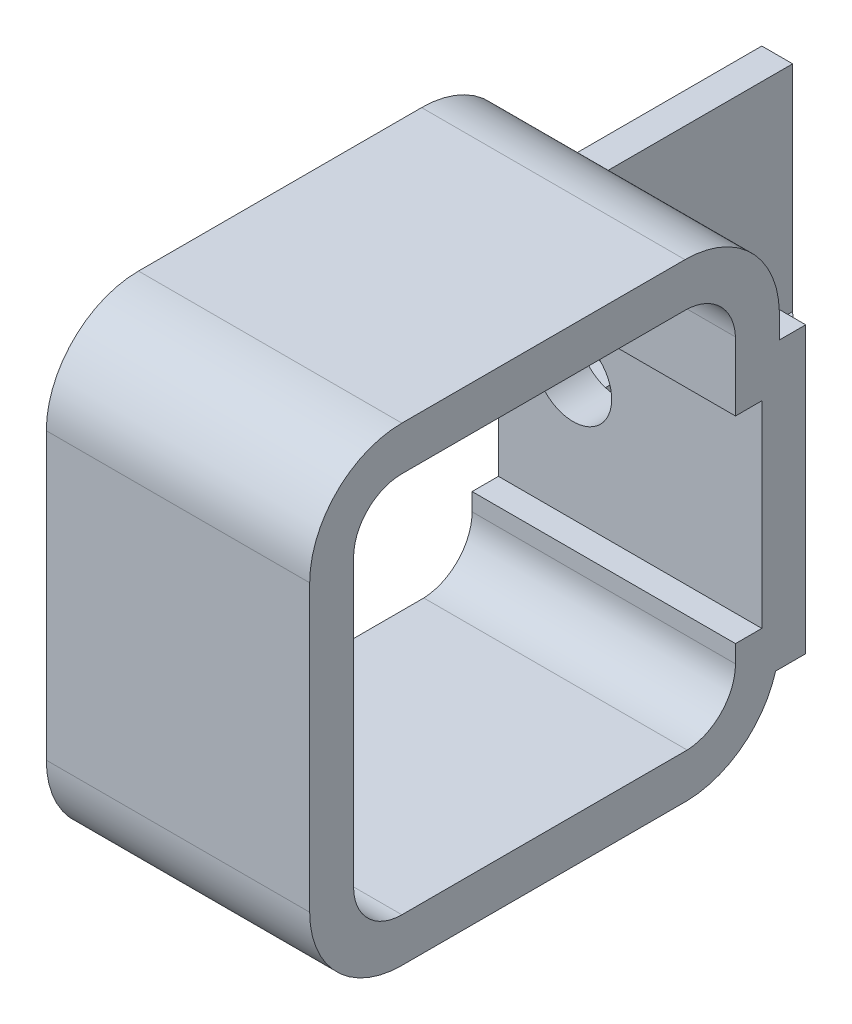
from build123d import *

# Parameters (mm, degrees)
BOSS_EXTRUDE1_DEPTH = 30
SKETCH3_R           = 4.4
CUT_EXTRUDE1_DEPTH  = 30
SKETCH4_W           = 3.511443211
SKETCH4_H           = 32.45
BOSS_EXTRUDE2_DEPTH = 25
SKETCH5_R           = 3
CUT_EXTRUDE2_DEPTH  = 20
SKETCH6_W           = 26.488556789
SKETCH6_H           = 8
BOSS_EXTRUDE3_DEPTH = 25
CUT_EXTRUDE5_DEPTH  = 8
SKETCH9_W           = 6
SKETCH9_H           = 15
CUT_EXTRUDE6_DEPTH  = 3.511443


with BuildPart() as part:
    # Sketch1 → Boss-Extrude1 (new body)
    with BuildSketch(Plane(origin=(0, 0, 0), x_dir=(0, 0, -1), z_dir=(1, 0, 0))):
        with BuildLine():
            ThreePointArc((24.712382734, 6.969258669), (32.225912197, 3.9087055), (35.462382734, -3.530741331))
            Line((35.462382734, -3.530741331), (35.462382734, -6.330741331))
            Line((35.462382734, -6.330741331), (38.462382734, -6.330741331))
            Line((38.462382734, -6.330741331), (38.462382734, -38.780741331))
            Line((38.462382734, -38.780741331), (35.035529086, -38.780741331))
            ThreePointArc((35.035529086, -38.780741331), (31.3038679, -44.275567943), (25.056259743, -46.530741331))
            Line((25.056259743, -46.530741331), (-7.537617266, -46.530741331))
            ThreePointArc((-7.537617266, -46.530741331), (-14.962238469, -43.455362534), (-18.037617266, -36.030741331))
            Line((-18.037617266, -36.030741331), (-18.037617266, -3.530741331))
            ThreePointArc((-18.037617266, -3.530741331), (-14.962238469, 3.893879871), (-7.537617266, 6.969258669))
            Line((-7.537617266, 6.969258669), (24.712382734, 6.969258669))
        make_face()
        with BuildLine():
            Line((-13.037617266, -3.530741331), (-13.037617266, -36.030741331))
            ThreePointArc((-13.037617266, -36.030741331), (-11.426704563, -39.919828628), (-7.537617266, -41.530741331))
            Line((-7.537617266, -41.530741331), (24.962382734, -41.530741331))
            ThreePointArc((24.962382734, -41.530741331), (28.865997514, -39.759198947), (30.462382734, -35.780741331))
            Line((30.462382734, -35.780741331), (30.462382734, -33.780741331))
            Line((30.462382734, -33.780741331), (33.462382734, -33.780741331))
            Line((33.462382734, -33.780741331), (33.462382734, -11.330741331))
            Line((33.462382734, -11.330741331), (30.462382734, -11.330741331))
            Line((30.462382734, -11.330741331), (30.462382734, -3.530741331))
            ThreePointArc((30.462382734, -3.530741331), (28.69084035, 0.372873449), (24.712382734, 1.969258669))
            Line((24.712382734, 1.969258669), (-7.537617266, 1.969258669))
            ThreePointArc((-7.537617266, 1.969258669), (-11.426704563, 0.358345965), (-13.037617266, -3.530741331))
        make_face(mode=Mode.SUBTRACT)
    extrude(amount=BOSS_EXTRUDE1_DEPTH)

    # Sketch3 → Cut-Extrude1 (cut)
    with BuildSketch(Plane(origin=(0, 0, -38.462382734), x_dir=(-1, 0, 0), z_dir=(0, 0, -1))):
        with Locations((-8.5, -19.730741331)):
            Circle(SKETCH3_R)
    extrude(amount=-CUT_EXTRUDE1_DEPTH, mode=Mode.SUBTRACT)

    # Sketch4 → Boss-Extrude2 (add)
    with BuildSketch(Plane(origin=(0, 0, -38.462382734), x_dir=(-1, 0, 0), z_dir=(0, 0, -1))):
        with Locations((-1.755721606, -22.555741331)):
            Rectangle(SKETCH4_W, SKETCH4_H)
    extrude(amount=BOSS_EXTRUDE2_DEPTH)

    # Sketch5 → Cut-Extrude2 (cut)
    with BuildSketch(Plane(origin=(3.511443211, 0, 0), x_dir=(0, 0, -1), z_dir=(1, 0, 0))):
        with Locations((53.462382734, -22.639729025)):
            Circle(SKETCH5_R)
    extrude(amount=-CUT_EXTRUDE2_DEPTH, mode=Mode.SUBTRACT)

    # Sketch6 → Boss-Extrude3 (add)
    with BuildSketch(Plane(origin=(0, 0, -38.462382734), x_dir=(-1, 0, 0), z_dir=(0, 0, -1))):
        with Locations((-16.755721606, -34.780741331)):
            Rectangle(SKETCH6_W, SKETCH6_H)
    extrude(amount=BOSS_EXTRUDE3_DEPTH)

    # Sketch8 → Cut-Extrude5 (cut)
    with BuildSketch(Plane(origin=(0, -30.780741331, 0), x_dir=(1, 0, 0), z_dir=(0, 1, 0))):
        Polygon((3.511443211, 63.462382734), (30, 38.462382734), (30, 63.462382734), align=None)
    extrude(amount=-CUT_EXTRUDE5_DEPTH, mode=Mode.SUBTRACT)

    # Sketch9 → Cut-Extrude6 (cut)
    with BuildSketch(Plane(origin=(3.511443211, 0, 0), x_dir=(0, 0, -1), z_dir=(1, 0, 0))):
        with Locations((41.462382734, -20.113548678)):
            Rectangle(SKETCH9_W, SKETCH9_H)
    extrude(amount=-CUT_EXTRUDE6_DEPTH, mode=Mode.SUBTRACT)


solid = part.part
